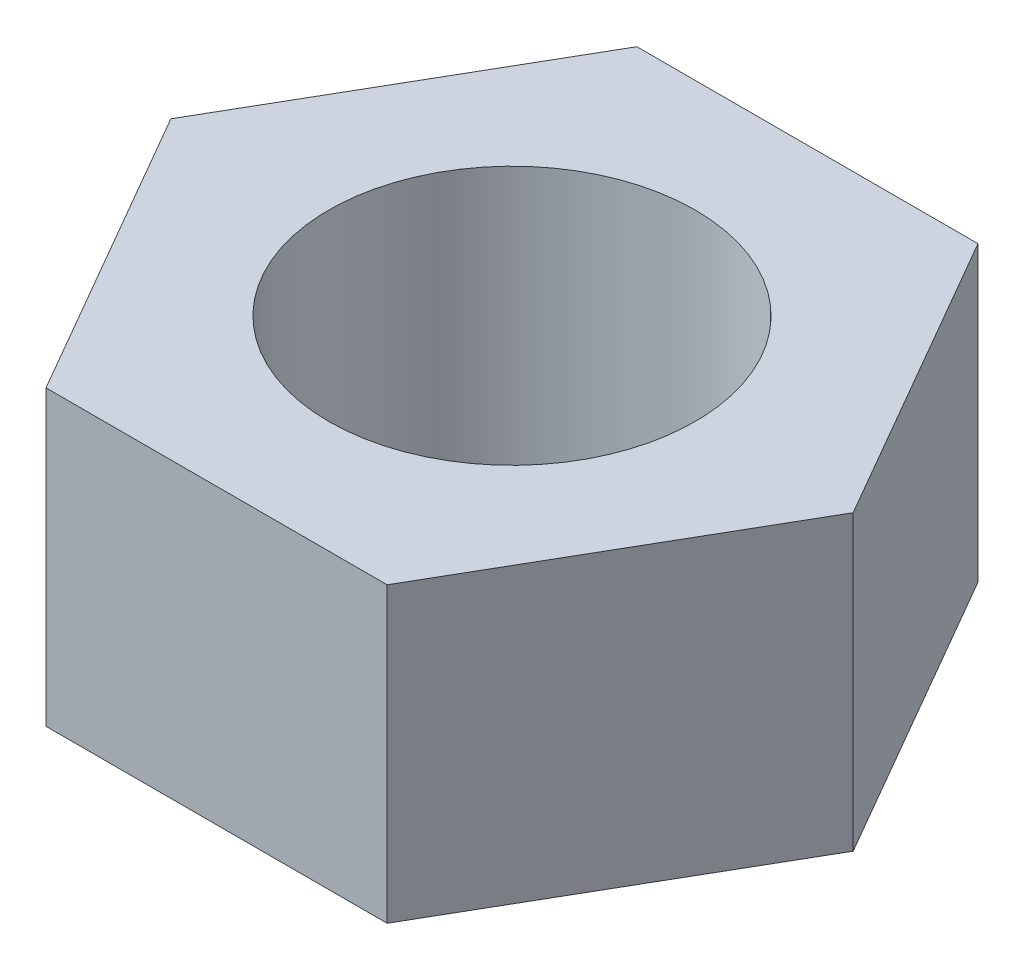
from build123d import *

# Parameters (mm, degrees)
SKETCH1_R           = 4
BOSS_EXTRUDE1_DEPTH = 6.4


with BuildPart() as part:
    # Sketch1 → Boss-Extrude1 (new body)
    with BuildSketch(Plane(origin=(0, 0, 0), x_dir=(1, 0, 0), z_dir=(0, 1, 0))):
        Polygon((3.723909236, 6.45), (-3.723909236, 6.45), (-7.447818473, 0), (-3.723909236, -6.45), (3.723909236, -6.45), (7.447818473, 0), align=None)
        Circle(SKETCH1_R, mode=Mode.SUBTRACT)
    extrude(amount=BOSS_EXTRUDE1_DEPTH)


solid = part.part
